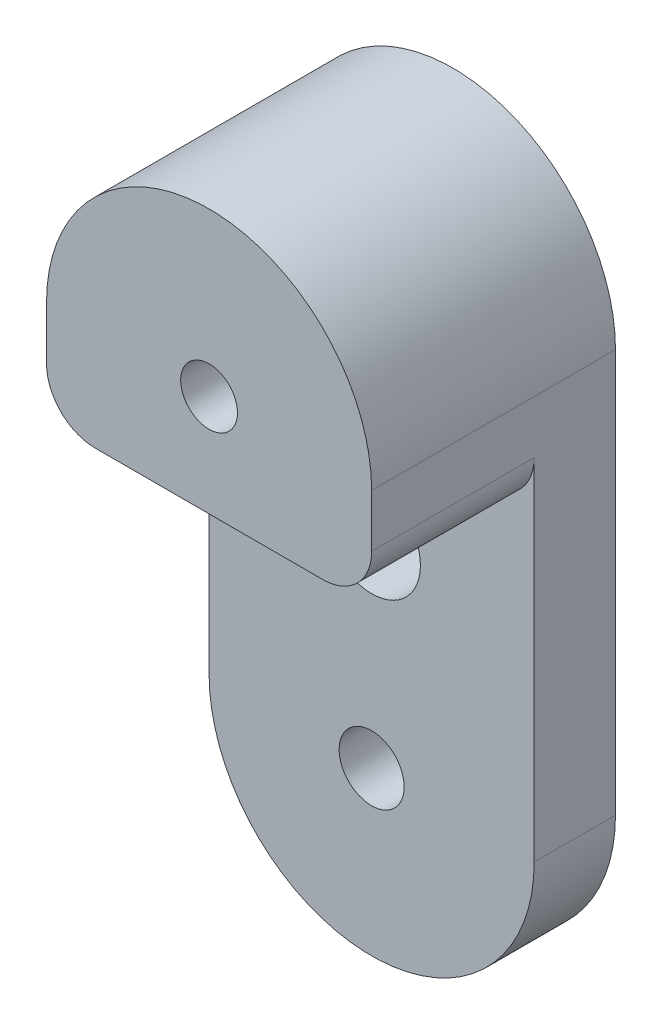
from build123d import *

# Parameters (mm, degrees)
SKETCH1_R           = 2
SKETCH1_R_2         = 3
BOSS_EXTRUDE1_DEPTH = 5
SKETCH1_3_R         = 1.74625
BOSS_EXTRUDE2_DEPTH = 15
FILLET1_R           = 3


with BuildPart() as part:
    # Sketch1 → Boss-Extrude1 (new body)
    with BuildSketch(Plane.XY):
        with BuildLine():
            Line((10, -24.8), (10, -6.25))
            Line((10, -6.25), (-10, -6.25))
            Line((-10, -6.25), (-10, -24.8))
            ThreePointArc((-10, -24.8), (0, -34.8), (10, -24.8))
        make_face()
        with Locations((0, -24.8)):
            Circle(SKETCH1_R, mode=Mode.SUBTRACT)
        with Locations((0, -12.5)):
            Circle(SKETCH1_R_2, mode=Mode.SUBTRACT)
    extrude(amount=BOSS_EXTRUDE1_DEPTH)

    # Sketch1_3 → Boss-Extrude2 (add)
    with BuildSketch(Plane.XY):
        with BuildLine():
            Line((10, -6.25), (10, 0))
            ThreePointArc((10, 0), (0, 10), (-10, 0))
            Line((-10, 0), (-10, -6.25))
            Line((-10, -6.25), (10, -6.25))
        make_face()
        Circle(SKETCH1_3_R, mode=Mode.SUBTRACT)
    extrude(amount=BOSS_EXTRUDE2_DEPTH)

    # Fillet1
    fillet1_edges = [part.edges().sort_by_distance(p)[0] for p in [
        (10, -6.25, 10),
        (-10, -6.25, 10),
    ]]
    fillet(fillet1_edges, radius=FILLET1_R)


solid = part.part
